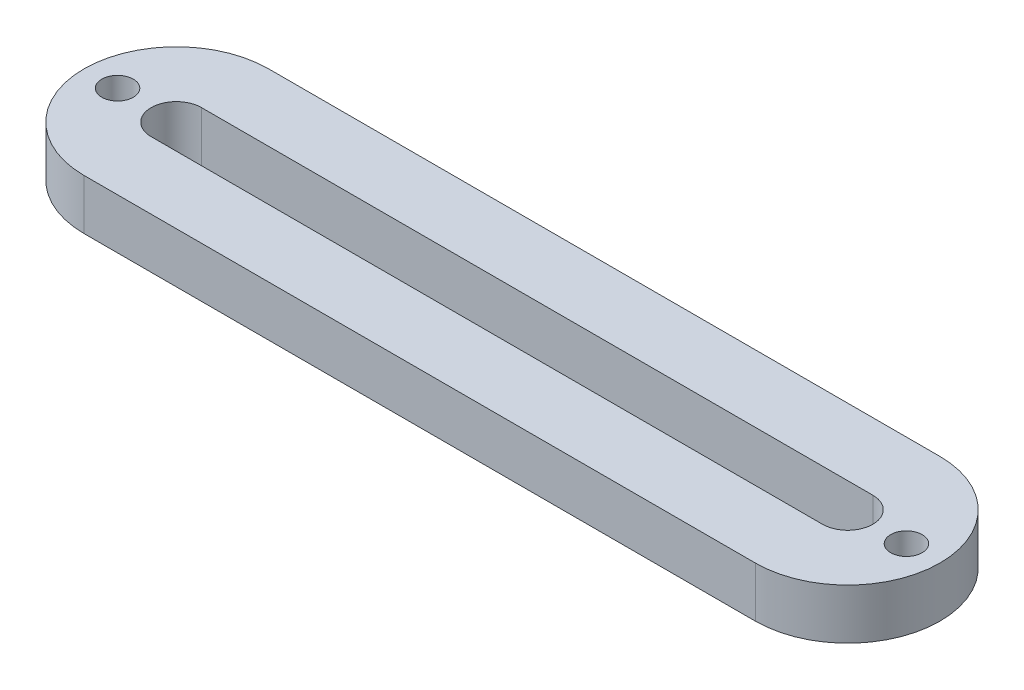
from build123d import *

# Parameters (mm, degrees)
CROQUIS1_R              = 1.875
SALIENTE_EXTRUIR1_DEPTH = 6


with BuildPart() as part:
    # Croquis1 → Saliente-Extruir1 (new body)
    with BuildSketch(Plane(origin=(0, 0, 0), x_dir=(1, 0, 0), z_dir=(0, 1, 0))):
        with BuildLine():
            Line((-40, 11), (40, 11))
            ThreePointArc((40, 11), (51, 0), (40, -11))
            Line((40, -11), (-40, -11))
            ThreePointArc((-40, -11), (-51, 0), (-40, 11))
        make_face()
        with Locations((-47, 0)):
            Circle(CROQUIS1_R, mode=Mode.SUBTRACT)
        with Locations((47, 0)):
            Circle(CROQUIS1_R, mode=Mode.SUBTRACT)
        with BuildLine():
            Line((-40, 3), (40, 3))
            ThreePointArc((40, 3), (43, 0), (40, -3))
            Line((40, -3), (-40, -3))
            ThreePointArc((-40, -3), (-43, 0), (-40, 3))
        make_face(mode=Mode.SUBTRACT)
    extrude(amount=SALIENTE_EXTRUIR1_DEPTH)


solid = part.part
